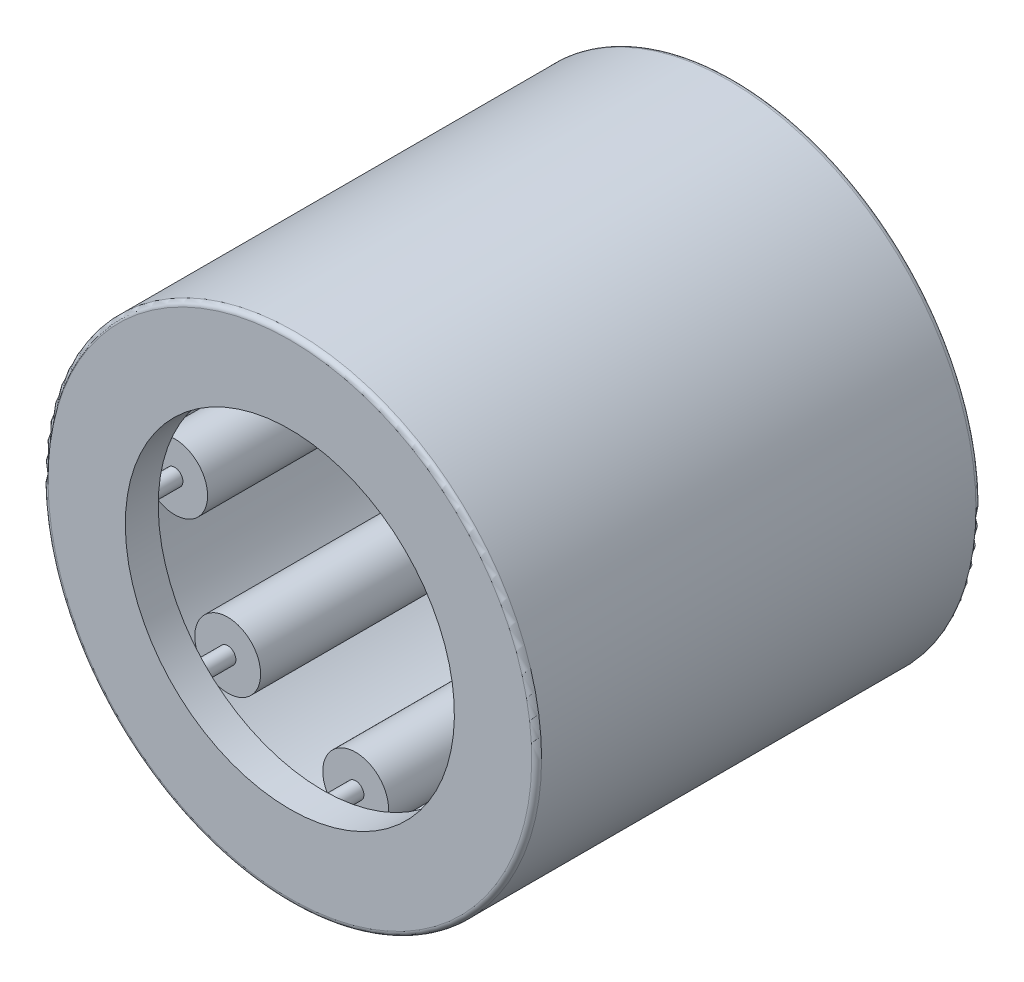
from build123d import *

# Parameters (mm, degrees)
SKETCH2_W         = 6.333333334
SKETCH2_H         = 0.5
SKETCH3_W         = 7.666666666
SKETCH3_H         = 0.166666666
CIRPATTERN1_COUNT = 8
CIRPATTERN1_ANGLE = 315
FILLET1_R         = 0.1


with BuildPart() as part:
    # Sketch7 → Revolve1 (revolve)
    with BuildSketch(Plane(origin=(0, 0, 0), x_dir=(0, 0, -1), z_dir=(1, 0, 0))):
        Polygon((-4.5, 5), (-4.5, 3.333333333), (-3.833333333, 3.333333333), (-3.833333333, 4.333333333), (3.833333333, 4.333333333), (3.833333333, 3.333333333), (4.5, 3.333333333), (4.5, 5), align=None)
    revolve(axis=Axis((0, 0, 4.5), (0, 0, -1)))

    # Fillet1
    fillet1_edges = [part.edges().sort_by_distance(p)[0] for p in [
        (0, -5, -4.5),
        (0, -5, 4.5),
    ]]
    fillet(fillet1_edges, radius=FILLET1_R)


with BuildPart() as body_2:
    # Sketch2 → Revolve2 (revolve)
    with BuildSketch(Plane(origin=(0, 0, 0), x_dir=(0, 0, -1), z_dir=(1, 0, 0))):
        with Locations((0, 4.083333333)):
            Rectangle(SKETCH2_W, SKETCH2_H)
    revolve(axis=Axis((0, 3.666666667, 3.166666667), (0, 0, -1)))


with BuildPart() as body_3:
    # Sketch3 → Revolve3 (revolve)
    with BuildSketch(Plane(origin=(0, 0, 0), x_dir=(0, 0, -1), z_dir=(1, 0, 0))):
        with Locations((0, 3.75)):
            Rectangle(SKETCH3_W, SKETCH3_H)
    revolve(axis=Axis((0, 3.666666667, 3.833333333), (0, 0, -1)))


with BuildPart() as cirpattern1_1:
    # CirPattern1: pattern copy
    add(body_2.part.rotate(Axis((0, 0, 4.5), (0, 0, -1)), 1 * CIRPATTERN1_ANGLE / (CIRPATTERN1_COUNT - 1)))


with BuildPart() as cirpattern1_2:
    # CirPattern1: pattern copy
    add(body_2.part.rotate(Axis((0, 0, 4.5), (0, 0, -1)), 2 * CIRPATTERN1_ANGLE / (CIRPATTERN1_COUNT - 1)))


with BuildPart() as cirpattern1_3:
    # CirPattern1: pattern copy
    add(body_2.part.rotate(Axis((0, 0, 4.5), (0, 0, -1)), 3 * CIRPATTERN1_ANGLE / (CIRPATTERN1_COUNT - 1)))


with BuildPart() as cirpattern1_4:
    # CirPattern1: pattern copy
    add(body_2.part.rotate(Axis((0, 0, 4.5), (0, 0, -1)), 4 * CIRPATTERN1_ANGLE / (CIRPATTERN1_COUNT - 1)))


with BuildPart() as cirpattern1_5:
    # CirPattern1: pattern copy
    add(body_2.part.rotate(Axis((0, 0, 4.5), (0, 0, -1)), 5 * CIRPATTERN1_ANGLE / (CIRPATTERN1_COUNT - 1)))


with BuildPart() as cirpattern1_6:
    # CirPattern1: pattern copy
    add(body_2.part.rotate(Axis((0, 0, 4.5), (0, 0, -1)), 6 * CIRPATTERN1_ANGLE / (CIRPATTERN1_COUNT - 1)))


with BuildPart() as cirpattern1_7:
    # CirPattern1: pattern copy
    add(body_2.part.rotate(Axis((0, 0, 4.5), (0, 0, -1)), 7 * CIRPATTERN1_ANGLE / (CIRPATTERN1_COUNT - 1)))


with BuildPart() as cirpattern1_8:
    # CirPattern1: pattern copy
    add(body_3.part.rotate(Axis((0, 0, 4.5), (0, 0, -1)), 1 * CIRPATTERN1_ANGLE / (CIRPATTERN1_COUNT - 1)))


with BuildPart() as cirpattern1_9:
    # CirPattern1: pattern copy
    add(body_3.part.rotate(Axis((0, 0, 4.5), (0, 0, -1)), 2 * CIRPATTERN1_ANGLE / (CIRPATTERN1_COUNT - 1)))


with BuildPart() as cirpattern1_10:
    # CirPattern1: pattern copy
    add(body_3.part.rotate(Axis((0, 0, 4.5), (0, 0, -1)), 3 * CIRPATTERN1_ANGLE / (CIRPATTERN1_COUNT - 1)))


with BuildPart() as cirpattern1_11:
    # CirPattern1: pattern copy
    add(body_3.part.rotate(Axis((0, 0, 4.5), (0, 0, -1)), 4 * CIRPATTERN1_ANGLE / (CIRPATTERN1_COUNT - 1)))


with BuildPart() as cirpattern1_12:
    # CirPattern1: pattern copy
    add(body_3.part.rotate(Axis((0, 0, 4.5), (0, 0, -1)), 5 * CIRPATTERN1_ANGLE / (CIRPATTERN1_COUNT - 1)))


with BuildPart() as cirpattern1_13:
    # CirPattern1: pattern copy
    add(body_3.part.rotate(Axis((0, 0, 4.5), (0, 0, -1)), 6 * CIRPATTERN1_ANGLE / (CIRPATTERN1_COUNT - 1)))


with BuildPart() as cirpattern1_14:
    # CirPattern1: pattern copy
    add(body_3.part.rotate(Axis((0, 0, 4.5), (0, 0, -1)), 7 * CIRPATTERN1_ANGLE / (CIRPATTERN1_COUNT - 1)))


solid = Compound([part.part, body_2.part, body_3.part, cirpattern1_1.part, cirpattern1_2.part, cirpattern1_3.part, cirpattern1_4.part, cirpattern1_5.part, cirpattern1_6.part, cirpattern1_7.part, cirpattern1_8.part, cirpattern1_9.part, cirpattern1_10.part, cirpattern1_11.part, cirpattern1_12.part, cirpattern1_13.part, cirpattern1_14.part])
